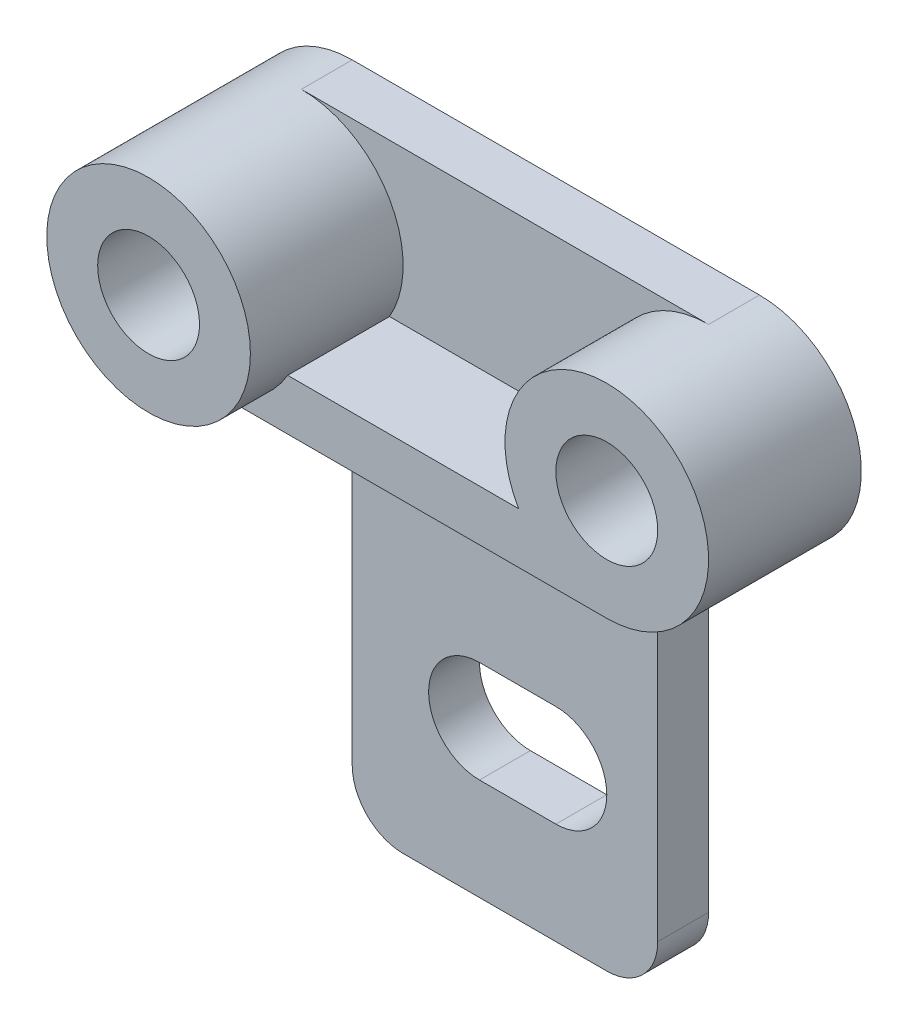
from build123d import *

# Parameters (mm, degrees)
SKETCH1_R                        = 20
BOSS_EXTRUDE1_DEPTH              = 30
SKETCH1_4_R                      = 20
BOSS_EXTRUDE2_DEPTH              = 40
SKETCH2_W                        = 80
SKETCH2_H                        = 40
BOSS_EXTRUDE3_DEPTH              = 10
SKETCH3_W                        = 80
SKETCH3_H                        = 10
BOSS_EXTRUDE4_DEPTH              = 20
BOSS_EXTRUDE7_DEPTH              = 10
CUT_EXTRUDE3_DEPTH               = 10
F_97_0_78740157_DIAMETER_HOLE1_D = 19.999999878


with BuildPart() as part:
    # Sketch1 → Boss-Extrude1 (new body)
    with BuildSketch(Plane.XY):
        with Locations((40, 3.000489608)):
            Circle(SKETCH1_R)
    extrude(amount=BOSS_EXTRUDE1_DEPTH)



with BuildPart() as body_2:
    # Sketch1_4 → Boss-Extrude2 (new body)
    with BuildSketch(Plane.XY):
        with Locations((-40, 3.000489608)):
            Circle(SKETCH1_4_R)
    extrude(amount=BOSS_EXTRUDE2_DEPTH)


with BuildPart() as part_1:
    add(part.part)

    add(body_2.part)  # Boss-Extrude3 merges body 2
    # Sketch2 → Boss-Extrude3 (add)
    with BuildSketch(Plane(origin=(0, 0, 0), x_dir=(-1, 0, 0), z_dir=(0, 0, -1))):
        with Locations((0, 3.000489608)):
            Rectangle(SKETCH2_W, SKETCH2_H)
    extrude(amount=-BOSS_EXTRUDE3_DEPTH)

    # Sketch3 → Boss-Extrude4 (add)
    with BuildSketch(Plane.XY.offset(10)):
        with Locations((0, -11.999510392)):
            Rectangle(SKETCH3_W, SKETCH3_H)
    extrude(amount=BOSS_EXTRUDE4_DEPTH)

    # Sketch6 → Boss-Extrude7 (add)
    with BuildSketch(Plane.XY.offset(10)):
        with BuildLine():
            Line((-30, -16.999510392), (30, -16.999510392))
            Line((30, -16.999510392), (30, -86.999510392))
            ThreePointArc((30, -86.999510392), (27.071067812, -94.070578204), (20, -96.999510392))
            Line((20, -96.999510392), (-20, -96.999510392))
            ThreePointArc((-20, -96.999510392), (-27.071067812, -94.070578204), (-30, -86.999510392))
            Line((-30, -86.999510392), (-30, -16.999510392))
        make_face()
    extrude(amount=-BOSS_EXTRUDE7_DEPTH)

    # Sketch7 → Cut-Extrude3 (cut)
    with BuildSketch(Plane.XY.offset(10)):
        with BuildLine():
            Line((-5, -56.999510392), (10, -56.999510392))
            ThreePointArc((10, -56.999510392), (20, -66.999510392), (10, -76.999510392))
            Line((10, -76.999510392), (-5, -76.999510392))
            ThreePointArc((-5, -76.999510392), (-15, -66.999510392), (-5, -56.999510392))
        make_face()
    extrude(amount=-CUT_EXTRUDE3_DEPTH, mode=Mode.SUBTRACT)

    # 97 _0.78740157_ Diameter Hole1 (through all)
    with Locations(Plane(origin=(0, 0, 0), x_dir=(-1, 0, 0), z_dir=(0, 0, -1))):
        with Locations((-40, 3.000489608), (40, 3.000489608)):
            Hole(F_97_0_78740157_DIAMETER_HOLE1_D / 2)


solid = part_1.part
